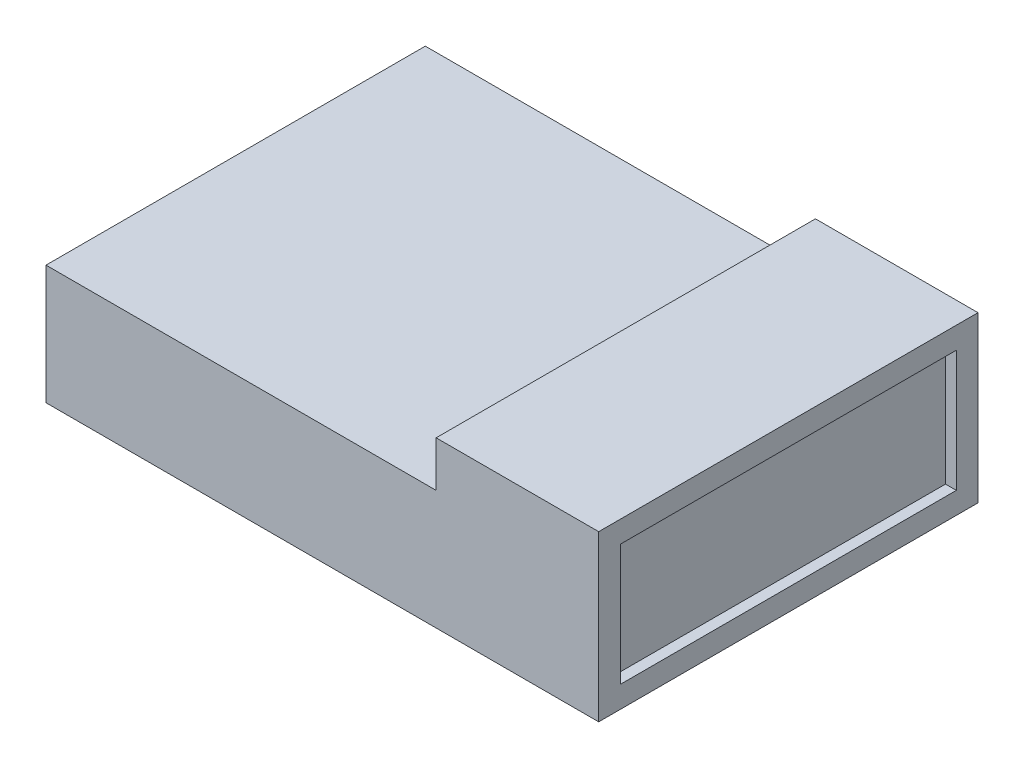
from build123d import *

# Parameters (mm, degrees)
SKETCH1_W           = 36
SKETCH1_H           = 35
BOSS_EXTRUDE1_DEPTH = 11
SKETCH1_3_W         = 15
SKETCH1_3_H         = 35
BOSS_EXTRUDE2_DEPTH = 15.2
SKETCH2_W           = 31
SKETCH2_H           = 11.2
CUT_EXTRUDE1_DEPTH  = 1


with BuildPart() as part:
    # Sketch1 → Boss-Extrude1 (new body)
    with BuildSketch(Plane(origin=(0, 0, 0), x_dir=(1, 0, 0), z_dir=(0, 1, 0))):
        with Locations((-7.5, 0)):
            Rectangle(SKETCH1_W, SKETCH1_H)
    extrude(amount=BOSS_EXTRUDE1_DEPTH)

    # Sketch1_3 → Boss-Extrude2 (add)
    with BuildSketch(Plane(origin=(0, 0, 0), x_dir=(1, 0, 0), z_dir=(0, 1, 0))):
        with Locations((18, 0)):
            Rectangle(SKETCH1_3_W, SKETCH1_3_H)
    extrude(amount=BOSS_EXTRUDE2_DEPTH)

    # Sketch2 → Cut-Extrude1 (cut)
    with BuildSketch(Plane(origin=(25.5, 0, 0), x_dir=(0, 0, -1), z_dir=(1, 0, 0))):
        with Locations((0, 7.6)):
            Rectangle(SKETCH2_W, SKETCH2_H)
    extrude(amount=-CUT_EXTRUDE1_DEPTH, mode=Mode.SUBTRACT)


solid = part.part
